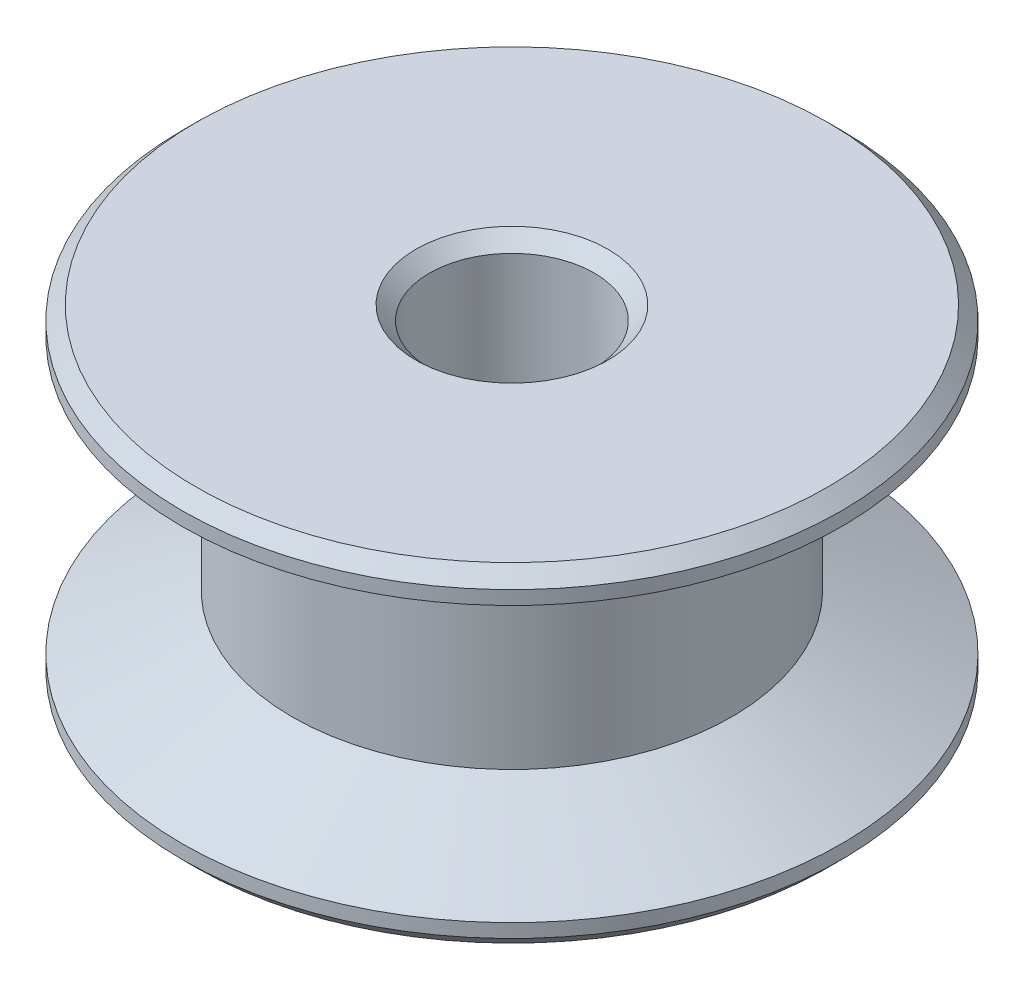
from build123d import *

# Parameters (mm, degrees)
SKETCH2_R               = 2.38125
CUT_EXTRUDE1_DEPTH      = 1
CUT_EXTRUDE1_DEPTH_BACK = 10.525
CHAMFER1_SIZE           = 0.396875


with BuildPart() as part:
    # Sketch1 → Revolve1 (revolve)
    with BuildSketch(Plane.XY):
        Polygon((0, 0), (9.525, 0), (9.525, 0.79375), (6.35, 2.38125), (6.35, 7.14375), (9.525, 8.73125), (9.525, 9.525), (0, 9.525), align=None)
    revolve(axis=Axis((0, 9.525, 0), (0, -1, 0)))

    # Sketch2 → Cut-Extrude1 (cut, two sides)
    with BuildSketch(Plane(origin=(0, 9.525, 0), x_dir=(1, 0, 0), z_dir=(0, 1, 0))) as cut_extrude1_sk:
        Circle(SKETCH2_R)
    extrude(amount=CUT_EXTRUDE1_DEPTH, mode=Mode.SUBTRACT)
    extrude(cut_extrude1_sk.sketch, amount=-CUT_EXTRUDE1_DEPTH_BACK, mode=Mode.SUBTRACT)

    # Chamfer1
    chamfer1_edges = [part.edges().sort_by_distance(p)[0] for p in [
        (-2.38125, 0, 0),
        (-2.38125, 9.525, 0),
        (-9.525, 9.525, 0),
        (-9.525, 0, 0),
    ]]
    chamfer(chamfer1_edges, length=CHAMFER1_SIZE)


solid = part.part
